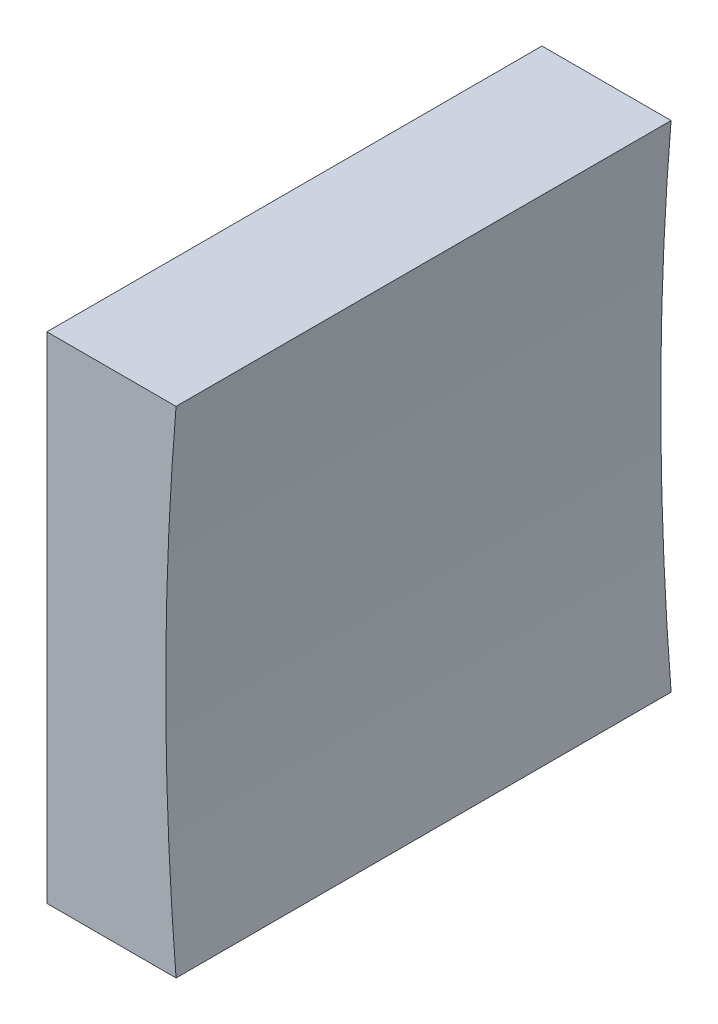
from build123d import *

# Parameters (mm, degrees)
EXTRUDE_1_DEPTH = 25


with BuildPart() as part:
    # 草图1 → 凸台-拉伸1 (new body)
    with BuildSketch(Plane.XY):
        with BuildLine():
            Line((284.707135631, 66.857929268), (284.707135631, 79.357929268))
            Line((284.707135631, 79.357929268), (291.228876343, 79.357929268))
            ThreePointArc((291.228876343, 79.357929268), (290.707135631, 66.857929268), (291.228876343, 54.357929268))
            Line((291.228876343, 54.357929268), (284.707135631, 54.357929268))
            Line((284.707135631, 54.357929268), (284.707135631, 66.857929268))
        make_face()
    extrude(amount=EXTRUDE_1_DEPTH)


solid = part.part
